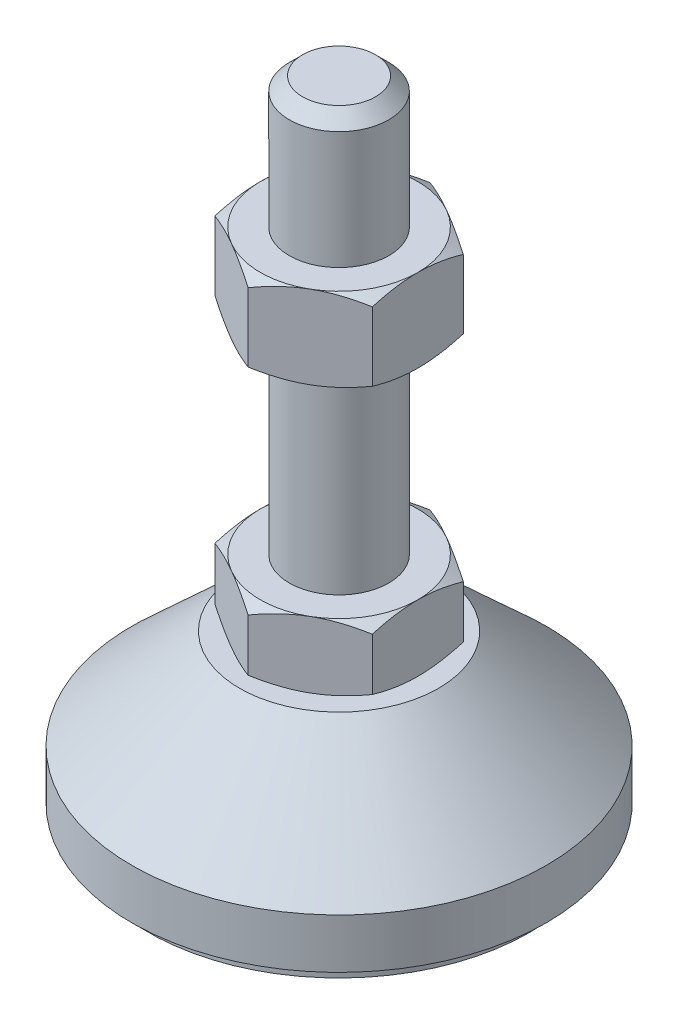
from build123d import *

# Parameters (mm, degrees)
EXTRUDE_1_DEPTH = 8
EXTRUDE_2_DEPTH = 10


with BuildPart() as part:
    # Эскиз1 → Повернуть1 (revolve)
    with BuildSketch(Plane.XY, mode=Mode.PRIVATE) as revolve_1_sk:
        Polygon((0, 0), (-23, 0), (-23, 2), (-25, 2), (-25, 8), (-12, 20), (-6, 20), (-6, 28), (-6, 76.4), (-4.4, 78), (0, 78), align=None)
    revolve(revolve_1_sk.sketch.rotate(Axis((0, 0, 0), (0, 1, 0)), 180), axis=Axis((0, 0, 0), (0, 1, 0)))  # turned: the seam where the file's is

    # Эскиз2 → Бобышка-Вытянуть1 (add)
    with BuildSketch(Plane(origin=(0, 20, 0), x_dir=(1, 0, 0), z_dir=(0, 1, 0))):
        Polygon((0, 10.969655115), (-9.5, 5.484827557), (-9.5, -5.484827557), (0, -10.969655115), (9.5, -5.484827557), (9.5, 5.484827557), align=None)
    extrude(amount=EXTRUDE_1_DEPTH)

    # Эскиз3 → Бобышка-Вытянуть2 (add)
    with BuildSketch(Plane(origin=(0, 52.2, 0), x_dir=(1, 0, 0), z_dir=(0, 1, 0))):
        Polygon((9.5, 5.484827557), (0, 10.969655115), (-9.5, 5.484827557), (-9.5, -5.484827557), (0, -10.969655115), (9.5, -5.484827557), align=None)
    extrude(amount=EXTRUDE_2_DEPTH)

    # Эскиз4 → Вырез-Повернуть2 (revolve, cut)
    with BuildSketch(Plane.XY, mode=Mode.PRIVATE) as cut_revolve_2_sk:
        Polygon((-18.160254038, 62.2), (-9.5, 62.2), (-18.160254038, 57.2), align=None)
        Polygon((-18.160254038, 52.2), (-18.160254038, 57.2), (-9.5, 52.2), align=None)
        Polygon((-16.42820323, 28), (-16.42820323, 24), (-9.5, 28), align=None)
        Polygon((-16.42820323, 24), (-16.42820323, 20), (-9.5, 20), align=None)
    revolve(cut_revolve_2_sk.sketch.rotate(Axis((0, 78, 0), (0, 1, 0)), 180), axis=Axis((0, 78, 0), (0, 1, 0)), mode=Mode.SUBTRACT)  # turned: the seam where the file's is


solid = part.part
